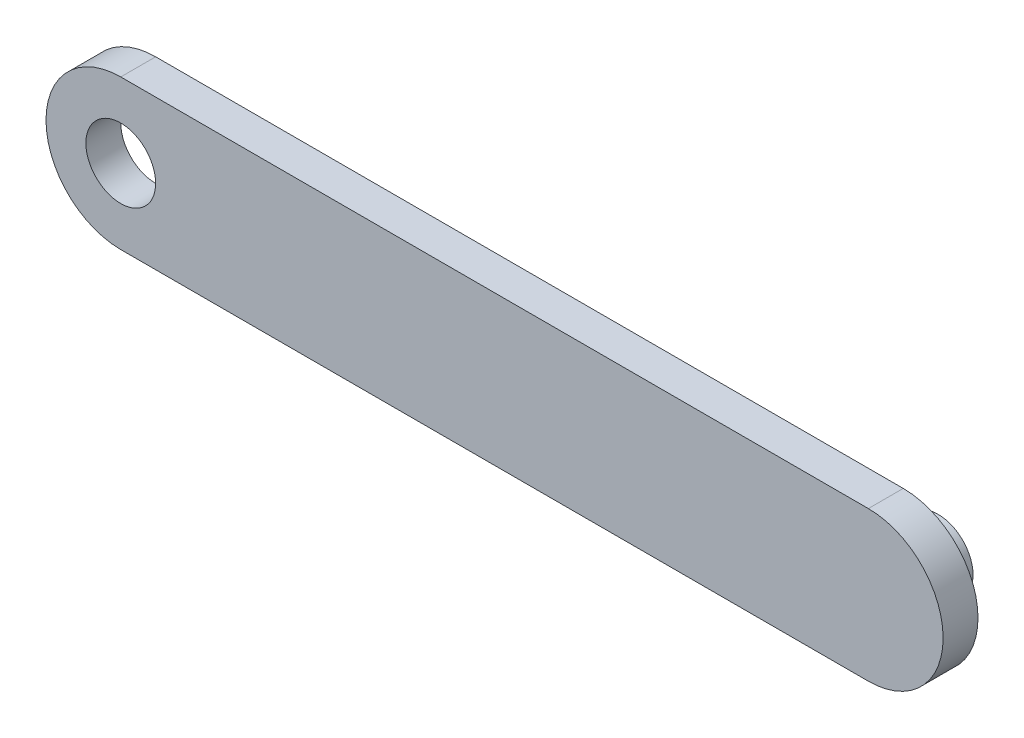
from build123d import *

# Parameters (mm, degrees)
BOSS_EXTRUDE1_DEPTH = 7
SKETCH2_R           = 7
BOSS_EXTRUDE3_DEPTH = 7
SKETCH3_R           = 7
CUT_EXTRUDE1_DEPTH  = 7


with BuildPart() as part:
    # Sketch1 → Boss-Extrude1 (new body)
    with BuildSketch(Plane.XY):
        with BuildLine():
            Line((-75, 15), (75, 15))
            ThreePointArc((75, 15), (90, 0), (75, -15))
            Line((75, -15), (-75, -15))
            ThreePointArc((-75, -15), (-90, 0), (-75, 15))
        make_face()
    extrude(amount=BOSS_EXTRUDE1_DEPTH)

    # Sketch2 → Boss-Extrude3 (add)
    with BuildSketch(Plane.XY):
        with Locations((75, 0)):
            Circle(SKETCH2_R)
    extrude(amount=-BOSS_EXTRUDE3_DEPTH)

    # Sketch3 → Cut-Extrude1 (cut)
    with BuildSketch(Plane(origin=(0, 0, 0), x_dir=(-1, 0, 0), z_dir=(0, 0, -1))):
        with Locations((75, 0)):
            Circle(SKETCH3_R)
    extrude(amount=-CUT_EXTRUDE1_DEPTH, mode=Mode.SUBTRACT)


solid = part.part
